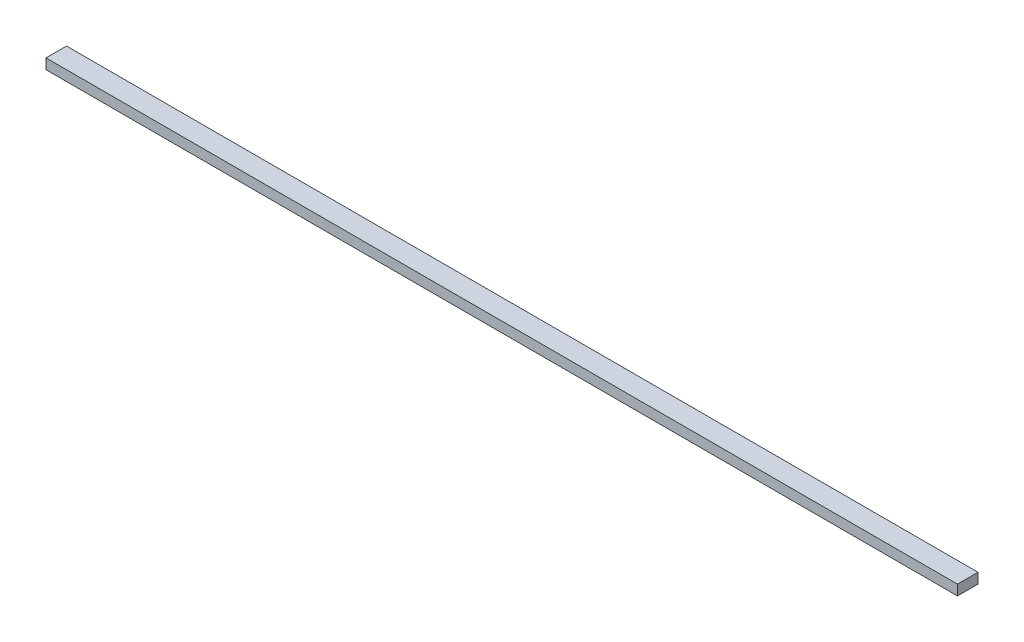
from build123d import *

# Parameters (mm, degrees)
SKETCH1_W           = 888.53
SKETCH1_H           = 20
BOSS_EXTRUDE1_DEPTH = 10


with BuildPart() as part:
    # Sketch1 → Boss-Extrude1 (new body)
    with BuildSketch(Plane(origin=(0, 0, 0), x_dir=(1, 0, 0), z_dir=(0, 1, 0))):
        Rectangle(SKETCH1_W, SKETCH1_H)
    extrude(amount=BOSS_EXTRUDE1_DEPTH)


solid = part.part
